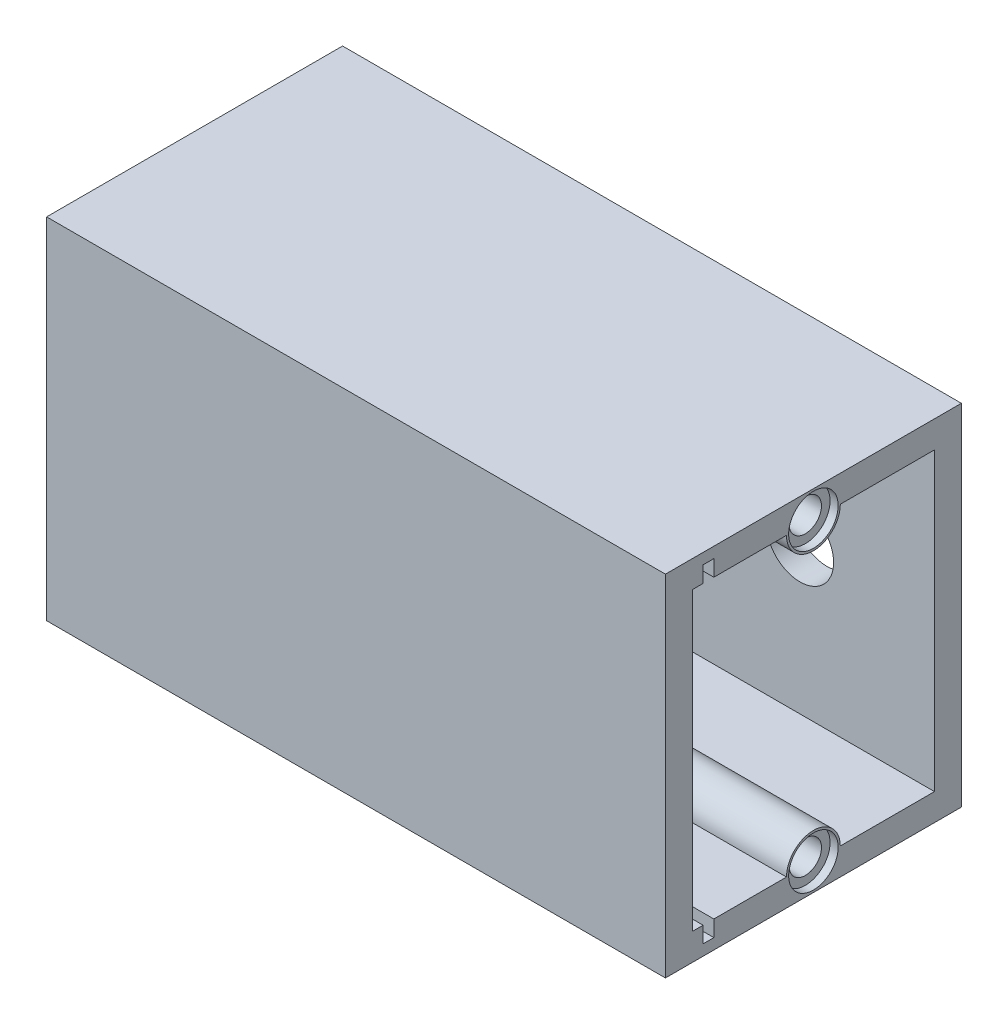
from build123d import *

# Parameters (mm, degrees)
ESQUISSE1_W             = 120
ESQUISSE1_H             = 65
ESQUISSE1_R             = 6.25
BOSS_EXTRU_1_DEPTH      = 5
ESQUISSE2_W             = 120
ESQUISSE2_H             = 65
ESQUISSE2_W_2           = 110
ESQUISSE2_H_2           = 55
BOSS_EXTRU_3_DEPTH      = 45
ESQUISSE4_W             = 120
ESQUISSE4_H             = 65
BOSS_EXTRU_4_DEPTH      = 5
ESQUISSE5_W             = 55
ESQUISSE5_H             = 65
ENL_V_MAT_EXTRU_1_DEPTH = 5
ESQUISSE6_W             = 2
ESQUISSE6_H             = 61
ENL_V_MAT_EXTRU_2_DEPTH = 62.25
BOSS_EXTRU_6_DEPTH      = 110
ESQUISSE8_R             = 3
ENL_V_MAT_EXTRU_3_DEPTH = 12
ESQUISSE9_R             = 4.6
ENL_V_MAT_EXTRU_7_DEPTH = 1.5


with BuildPart() as part:
    # Esquisse1 → Boss.-Extru.1 (new body)
    with BuildSketch(Plane.XY):
        with Locations((60, 32.5)):
            Rectangle(ESQUISSE1_W, ESQUISSE1_H)
        with Locations((30, 32.5)):
            Circle(ESQUISSE1_R, mode=Mode.SUBTRACT)
        with Locations((90, 32.5)):
            Circle(ESQUISSE1_R, mode=Mode.SUBTRACT)
    extrude(amount=BOSS_EXTRU_1_DEPTH)

    # Esquisse2 → Boss.-Extru.3 (add)
    with BuildSketch(Plane.XY.offset(5)):
        with Locations((60, 32.5)):
            Rectangle(ESQUISSE2_W, ESQUISSE2_H)
        with Locations((60, 32.5)):
            Rectangle(ESQUISSE2_W_2, ESQUISSE2_H_2, mode=Mode.SUBTRACT)
    extrude(amount=BOSS_EXTRU_3_DEPTH)

    # Esquisse4 → Boss.-Extru.4 (add)
    with BuildSketch(Plane.XY.offset(50)):
        with Locations((60, 32.5)):
            Rectangle(ESQUISSE4_W, ESQUISSE4_H)
    extrude(amount=BOSS_EXTRU_4_DEPTH)

    # Esquisse5 → Enlèv. mat.-Extru.1 (cut)
    with BuildSketch(Plane(origin=(120, 0, 0), x_dir=(0, 0, -1), z_dir=(1, 0, 0))):
        with Locations((-27.5, 32.5)):
            Rectangle(ESQUISSE5_W, ESQUISSE5_H)
    extrude(amount=-ENL_V_MAT_EXTRU_1_DEPTH, mode=Mode.SUBTRACT)

    # Esquisse6 → Enlèv. mat.-Extru.2 (cut)
    with BuildSketch(Plane(origin=(115, 0, 0), x_dir=(0, 0, -1), z_dir=(1, 0, 0))):
        with Locations((-47, 32.5)):
            Rectangle(ESQUISSE6_W, ESQUISSE6_H)
    extrude(amount=-ENL_V_MAT_EXTRU_2_DEPTH, mode=Mode.SUBTRACT)

    # Esquisse7 → Boss.-Extru.6 (add)
    with BuildSketch(Plane(origin=(115, 0, 0), x_dir=(0, 0, -1), z_dir=(1, 0, 0))):
        with BuildLine():
            Line((-22.5, 60), (-32.5, 60))
            ThreePointArc((-32.5, 60), (-27.5, 55), (-22.5, 60))
        make_face()
        with BuildLine():
            Line((-32.5, 5), (-22.5, 5))
            ThreePointArc((-22.5, 5), (-27.5, 10), (-32.5, 5))
        make_face()
    extrude(amount=-BOSS_EXTRU_6_DEPTH)

    # Esquisse8 → Enlèv. mat.-Extru.3 (cut)
    with BuildSketch(Plane(origin=(115, 0, 0), x_dir=(0, 0, -1), z_dir=(1, 0, 0))):
        with Locations((-27.5, 60)):
            Circle(ESQUISSE8_R)
        with Locations((-27.5, 5)):
            Circle(ESQUISSE8_R)
    extrude(amount=-ENL_V_MAT_EXTRU_3_DEPTH, mode=Mode.SUBTRACT)

    # Esquisse9 → Enlèv. mat.-Extru.7 (cut)
    with BuildSketch(Plane(origin=(115, 0, 0), x_dir=(0, 0, -1), z_dir=(1, 0, 0))):
        with Locations((-27.5, 60)):
            Circle(ESQUISSE9_R)
        with Locations((-27.5, 5)):
            Circle(ESQUISSE9_R)
    extrude(amount=-ENL_V_MAT_EXTRU_7_DEPTH, mode=Mode.SUBTRACT)


solid = part.part
